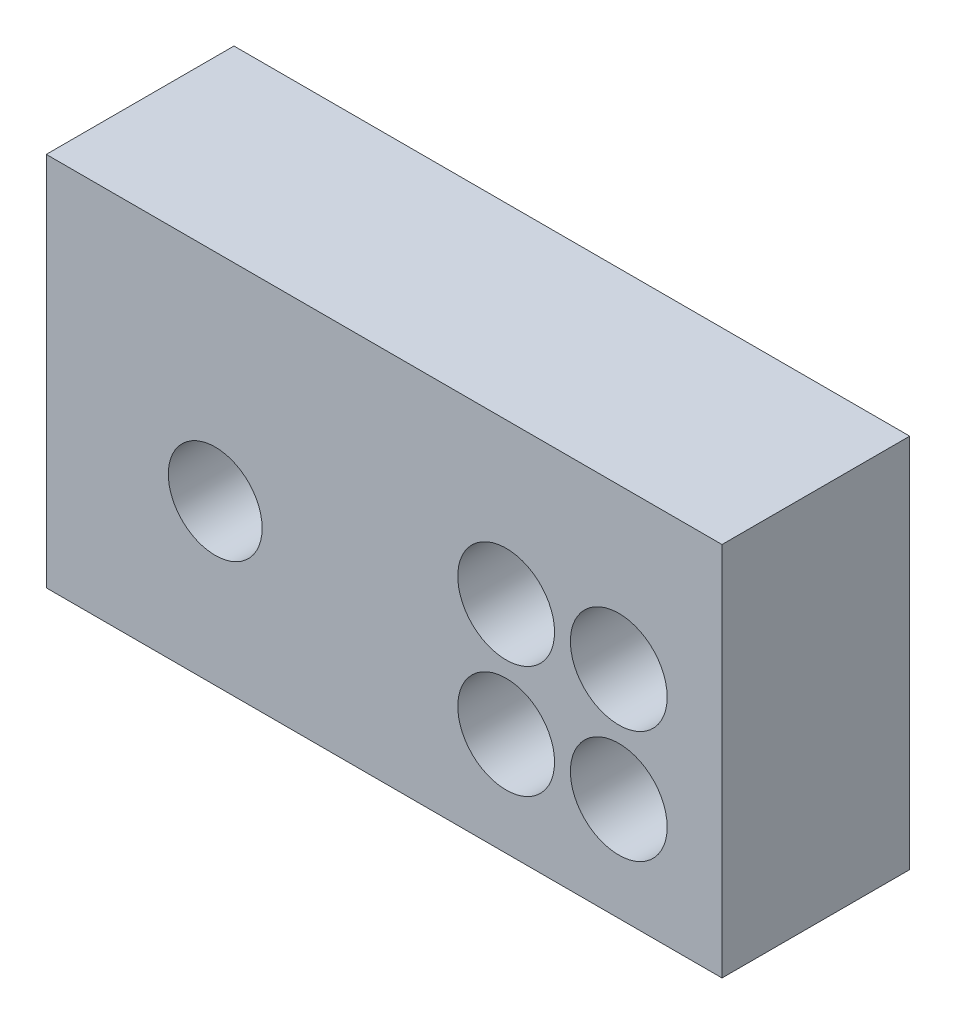
from build123d import *

# Parameters (mm, degrees)
SKETCH1_W          = 3.6
SKETCH1_H          = 2
EXTRUDE1_DEPTH     = 1
SKETCH2_R          = 0.25
CUT_EXTRUDE1_DEPTH = 2
SKETCH3_R          = 0.25781
CUT_EXTRUDE2_DEPTH = 2


with BuildPart() as part:
    # Sketch1 → Extrude1 (new body)
    with BuildSketch(Plane.XY):
        with Locations((-47.470942408, 24.056457243)):
            Rectangle(SKETCH1_W, SKETCH1_H)
    extrude(amount=EXTRUDE1_DEPTH)

    # Sketch2 → Cut-Extrude1 (cut, through all)
    with BuildSketch(Plane.XY.offset(1)):
        with Locations((-48.370942408, 23.906457243)):
            Circle(SKETCH2_R)
    extrude(amount=-CUT_EXTRUDE1_DEPTH, mode=Mode.SUBTRACT)

    # Sketch3 → Cut-Extrude2 (cut, through all)
    with BuildSketch(Plane.XY.offset(1)):
        with Locations((-46.820942408, 24.206457243)):
            Circle(SKETCH3_R)
        with Locations((-46.820942408, 23.606457243)):
            Circle(SKETCH3_R)
        with Locations((-46.220942408, 23.606457243)):
            Circle(SKETCH3_R)
        with Locations((-46.220942408, 24.206457243)):
            Circle(SKETCH3_R)
    extrude(amount=-CUT_EXTRUDE2_DEPTH, mode=Mode.SUBTRACT)


solid = part.part
